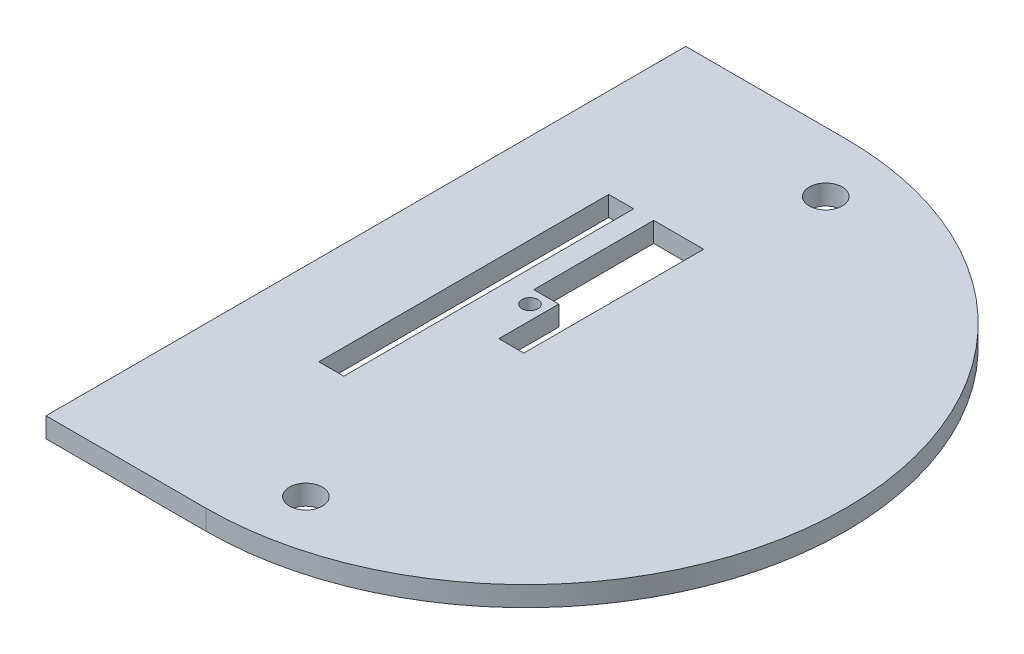
from build123d import *

# Parameters (mm, degrees)
CROQUIS2_W                = 2.5
CROQUIS2_H                = 29
CROQUIS2_R                = 0.8
SALIENTE_EXTRUIR2_DEPTH   = 2
TALADRO_ROSCADO_M41_D     = 3.3
TALADRO_ROSCADO_M41_DEPTH = 11.5
TALADRO_ROSCADO_M41_TIP   = 0.991420021


with BuildPart() as part:
    # Croquis2 → Saliente-Extruir2 (new body)
    with BuildSketch(Plane(origin=(0, 0, 0), x_dir=(1, 0, 0), z_dir=(0, 1, 0))):
        with BuildLine():
            Line((-69.290093462, 11.720598128), (-71.290093462, 11.720598128))
            Line((-71.290093462, 11.720598128), (-71.290093462, -52.279401872))
            Line((-71.290093462, -52.279401872), (-55.290093462, -52.279401872))
            ThreePointArc((-55.290093462, -52.279401872), (-23.290093462, -20.279401872), (-55.290093462, 11.720598128))
            Line((-55.290093462, 11.720598128), (-69.290093462, 11.720598128))
        make_face()
        with Locations((-61.073318824, -19.453109229)):
            Rectangle(CROQUIS2_W, CROQUIS2_H, mode=Mode.SUBTRACT)
        with Locations((-56.754226246, -18.397495979)):
            Circle(CROQUIS2_R, mode=Mode.SUBTRACT)
        Polygon((-57.823318824, -16.953109229), (-57.823318824, -4.953109229), (-52.823318824, -4.953109229), (-52.823318824, -22.953109229), (-55.323318824, -22.953109229), (-55.323318824, -16.953109229), align=None, mode=Mode.SUBTRACT)
    extrude(amount=SALIENTE_EXTRUIR2_DEPTH)

    # Taladro roscado M41
    with Locations(Plane(origin=(0, 2, 0), x_dir=(1, 0, 0), z_dir=(0, 1, 0))):
        with Locations((-51.290093462, 5.720598128), (-51.290093462, -46.279401872)):
            Hole(TALADRO_ROSCADO_M41_D / 2, depth=TALADRO_ROSCADO_M41_DEPTH)
            with Locations((0, 0, -(TALADRO_ROSCADO_M41_DEPTH + TALADRO_ROSCADO_M41_TIP / 2))):  # 118° drill point
                Cone(0, TALADRO_ROSCADO_M41_D / 2, TALADRO_ROSCADO_M41_TIP, mode=Mode.SUBTRACT)


solid = part.part
